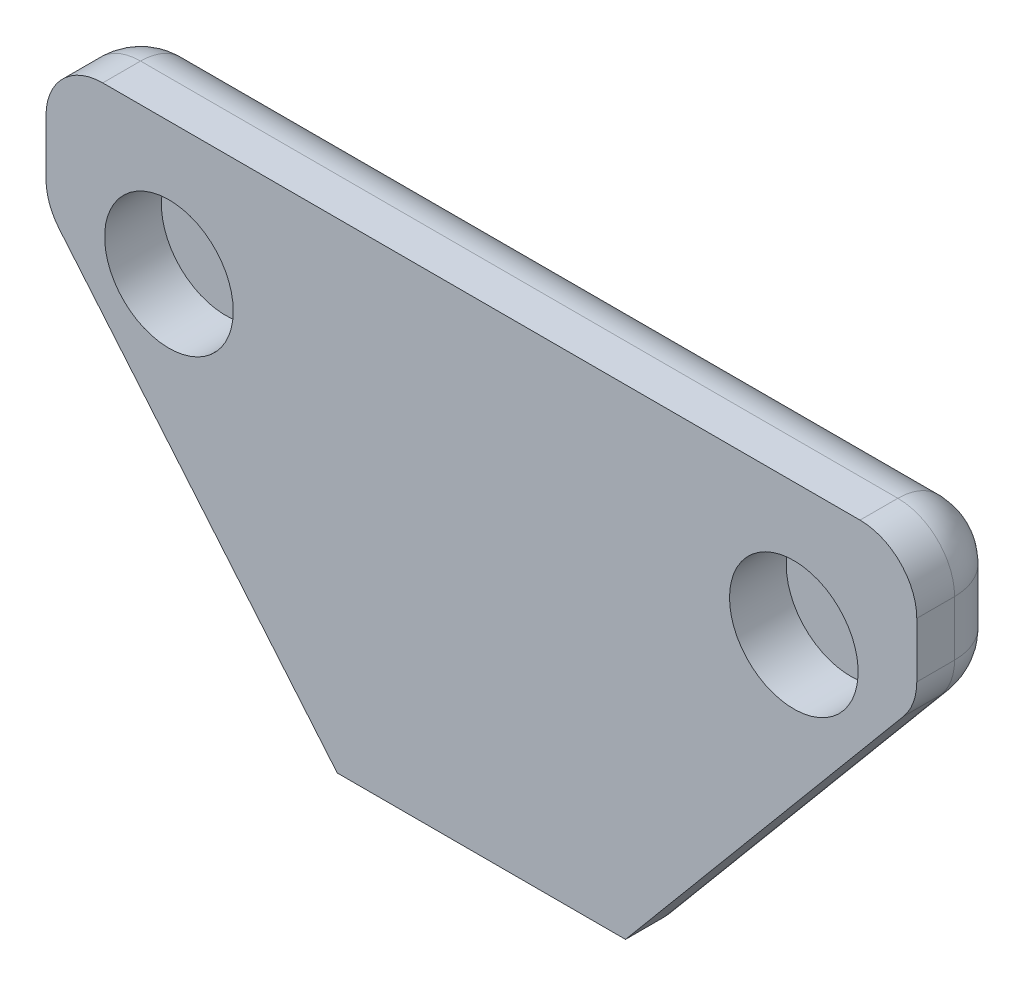
from build123d import *

# Parameters (mm, degrees)
BOSS_EXTRUDE1_DEPTH = 2.5
SKETCH2_R           = 1.7
CUT_EXTRUDE1_DEPTH  = 1.5
FILLET1_R           = 1.5


with BuildPart() as part:
    # Sketch1 → Boss-Extrude1 (new body)
    with BuildSketch(Plane.XY):
        Polygon((-6.06419618, 12.7), (-6.06419618, 9.2), (1.63580382, 0), (5.44580382, 0), (5.44580382, 12.7), align=None)
    extrude(amount=BOSS_EXTRUDE1_DEPTH)

    # Sketch2 → Cut-Extrude1 (cut)
    with BuildSketch(Plane.XY.offset(2.5)):
        with Locations((-2.81419618, 9.2)):
            Circle(SKETCH2_R)
    extrude(amount=-CUT_EXTRUDE1_DEPTH, mode=Mode.SUBTRACT)

    # Fillet1
    fillet1_edges = [part.edges().sort_by_distance(p)[0] for p in [
        (3.54080382, 0, 0),
        (-2.21419618, 4.6, 0),
        (-6.06419618, 10.95, 0),
        (-0.30919618, 12.7, 0),
        (-6.06419618, 9.2, 1.25),
        (-6.06419618, 12.7, 1.25),
    ]]
    fillet(fillet1_edges, radius=FILLET1_R)

    # Mirror2: part across plane


with BuildPart() as part_1:
    add(part.part)
    add(part.part.mirror(Plane(origin=(5.44580382, 0, 2.5), x_dir=(0, 0, 1), z_dir=(-1, 0, 0))))


solid = part_1.part
